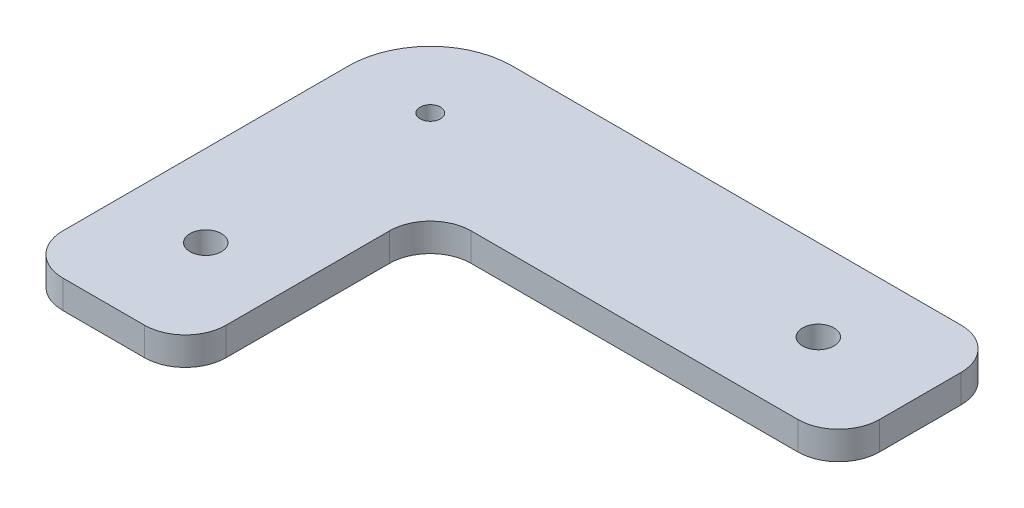
from build123d import *

# Parameters (mm, degrees)
BOSS_EXTRUDE1_DEPTH = 6.9
FILLET1_R           = 10
FILLET2_R           = 20
SKETCH3_R           = 2.5
CUT_EXTRUDE2_DEPTH  = 7.9
SKETCH2_R           = 3.85
CUT_EXTRUDE1_DEPTH  = 7.9


with BuildPart() as part:
    # Sketch1 → Boss-Extrude1 (new body)
    with BuildSketch(Plane(origin=(0, 0, 0), x_dir=(1, 0, 0), z_dir=(0, 1, 0))):
        Polygon((0, 0), (0, 100), (140, 100), (140, 60), (40, 60), (40, 0), align=None)
    extrude(amount=BOSS_EXTRUDE1_DEPTH)

    # Fillet1
    fillet1_edges = [part.edges().sort_by_distance(p)[0] for p in [
        (0, 3.45, 0),
        (140, 3.45, -100),
        (140, 3.45, -60),
        (40, 3.45, -60),
        (40, 3.45, 0),
    ]]
    fillet(fillet1_edges, radius=FILLET1_R)

    # Fillet2
    fillet2_edges = [part.edges().sort_by_distance(p)[0] for p in [
        (0, 3.45, -100),
    ]]
    fillet(fillet2_edges, radius=FILLET2_R)

    # Sketch3 → Cut-Extrude2 (cut, through all)
    with BuildSketch(Plane(origin=(0, 6.9, 0), x_dir=(1, 0, 0), z_dir=(0, 1, 0))):
        with Locations((20, 80)):
            Circle(SKETCH3_R)
    extrude(amount=-CUT_EXTRUDE2_DEPTH, mode=Mode.SUBTRACT)

    # Sketch2 → Cut-Extrude1 (cut, through all)
    with BuildSketch(Plane(origin=(0, 6.9, 0), x_dir=(1, 0, 0), z_dir=(0, 1, 0))):
        with Locations((20, 25)):
            Circle(SKETCH2_R)
        with Locations((115, 80)):
            Circle(SKETCH2_R)
    extrude(amount=-CUT_EXTRUDE1_DEPTH, mode=Mode.SUBTRACT)


solid = part.part
